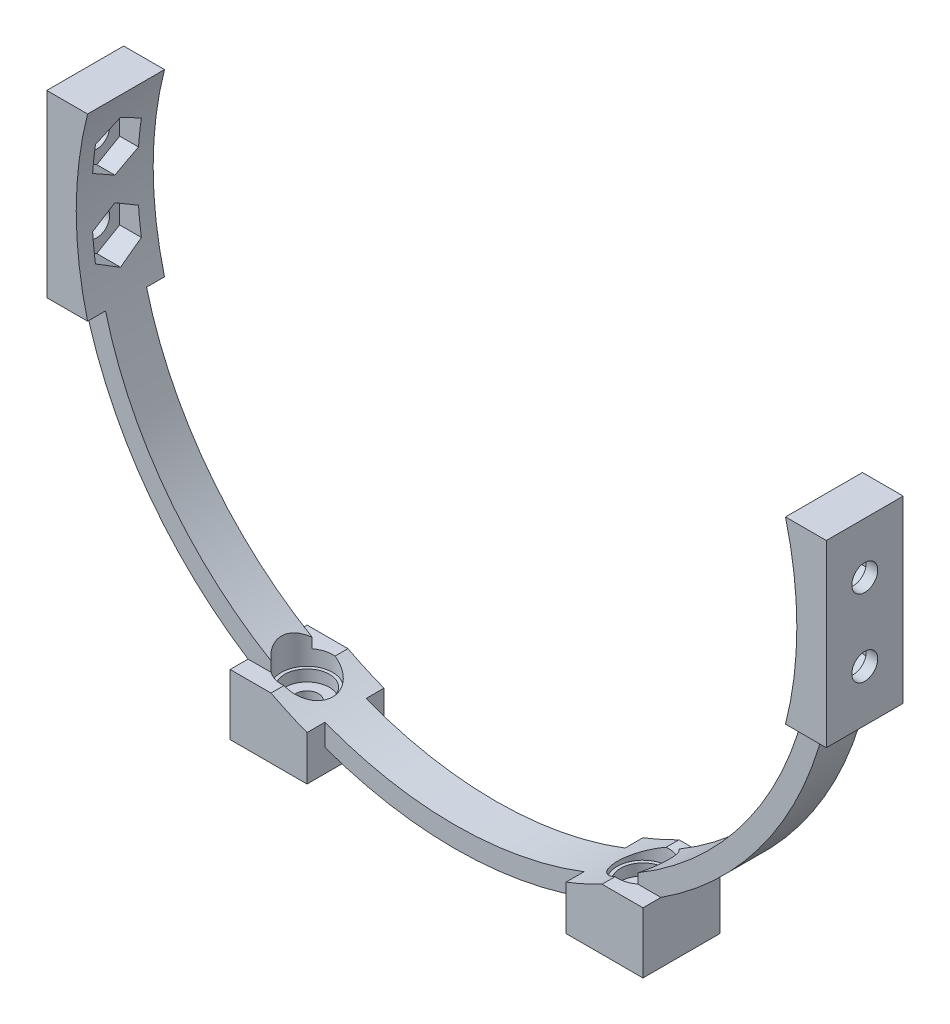
from build123d import *

# Parameters (mm, degrees)
BOSS_EXTRUDE1_DEPTH                            = 4
BOSS_EXTRUDE2_DEPTH                            = 7.5
CUT_EXTRUDE1_DEPTH                             = 3.5
F_8_0_199_DIAMETER_HOLE1_AT_2_COUNT            = 2
F_8_0_199_DIAMETER_HOLE1_AT_2_PITCH            = 15
BOSS_EXTRUDE3_REACH                            = 108.518
BOSS_EXTRUDE3_DIRECTION_2_REACH                = 108.518
SKETCH6_R                                      = 5
CUT_EXTRUDE2_DEPTH                             = 3.5
CUT_EXTRUDE2_DEPTH_BACK                        = 3
CBORE_FOR_8_BUTTON_HEAD_CAP_SCREW1_D           = 4.4958
CBORE_FOR_8_BUTTON_HEAD_CAP_SCREW1_DEPTH       = 11.649325414
CBORE_FOR_8_BUTTON_HEAD_CAP_SCREW1_CBORE_D     = 8.73252
CBORE_FOR_8_BUTTON_HEAD_CAP_SCREW1_CBORE_DEPTH = 2.2098
CBORE_FOR_8_BUTTON_HEAD_CAP_SCREW1_TIP         = 1.350674586


with BuildPart() as part:
    # Sketch1 → Boss-Extrude1 (new, symmetric)
    with BuildSketch(Plane.XY):
        with BuildLine():
            Line((-76, 17.5), (-76, 0))
            Line((-76, 0), (-76, -17.5))
            Line((-76, -17.5), (-72.163391169, -17.5))
            Line((-72.163391169, -17.5), (-68.04053957, -17.5))
            ThreePointArc((-68.04053957, -17.5), (-69.699186267, -8.81977657), (-70.255, 0))
            ThreePointArc((-70.255, 0), (-69.699186267, 8.81977657), (-68.04053957, 17.5))
            Line((-68.04053957, 17.5), (-70.255, 17.5))
            Line((-70.255, 17.5), (-76, 17.5))
        make_face()
        with BuildLine():
            Line((-68.04053957, -17.5), (-72.163391169, -17.5))
            ThreePointArc((-72.163391169, -17.5), (0, -74.255), (72.163391169, -17.5))
            Line((72.163391169, -17.5), (68.04053957, -17.5))
            ThreePointArc((68.04053957, -17.5), (0, -70.255), (-68.04053957, -17.5))
        make_face()
        with BuildLine():
            Line((68.04053957, -17.5), (72.163391169, -17.5))
            Line((72.163391169, -17.5), (76, -17.5))
            Line((76, -17.5), (76, 0))
            Line((76, 0), (76, 17.5))
            Line((76, 17.5), (70.255, 17.5))
            Line((70.255, 17.5), (68.04053957, 17.5))
            ThreePointArc((68.04053957, 17.5), (69.699186267, 8.81977657), (70.255, 0))
            ThreePointArc((70.255, 0), (69.699186267, -8.81977657), (68.04053957, -17.5))
        make_face()
    extrude(amount=BOSS_EXTRUDE1_DEPTH, both=True)

    # Sketch1_5 → Boss-Extrude2 (add, symmetric)
    with BuildSketch(Plane.XY):
        with BuildLine():
            Line((-76, 17.5), (-76, 0))
            Line((-76, 0), (-76, -17.5))
            Line((-76, -17.5), (-72.163391169, -17.5))
            Line((-72.163391169, -17.5), (-68.04053957, -17.5))
            ThreePointArc((-68.04053957, -17.5), (-69.699186267, -8.81977657), (-70.255, 0))
            ThreePointArc((-70.255, 0), (-69.699186267, 8.81977657), (-68.04053957, 17.5))
            Line((-68.04053957, 17.5), (-70.255, 17.5))
            Line((-70.255, 17.5), (-76, 17.5))
        make_face()
        with BuildLine():
            Line((68.04053957, -17.5), (72.163391169, -17.5))
            Line((72.163391169, -17.5), (76, -17.5))
            Line((76, -17.5), (76, 0))
            Line((76, 0), (76, 17.5))
            Line((76, 17.5), (70.255, 17.5))
            Line((70.255, 17.5), (68.04053957, 17.5))
            ThreePointArc((68.04053957, 17.5), (69.699186267, 8.81977657), (70.255, 0))
            ThreePointArc((70.255, 0), (69.699186267, -8.81977657), (68.04053957, -17.5))
        make_face()
    extrude(amount=BOSS_EXTRUDE2_DEPTH, both=True)

    # Sketch2 → Cut-Extrude1 (cut, symmetric)
    with BuildSketch(Plane.ZY.offset(-70.255)):
        Polygon((0, 2.332715091), (4.475, 4.916357545), (4.475, 10.083642455), (0, 12.667284909), (-4.475, 10.083642455), (-4.475, 4.916357545), align=None)
        Polygon((0, -12.667284909), (4.475, -10.083642455), (4.475, -4.916357545), (0, -2.332715091), (-4.475, -4.916357545), (-4.475, -10.083642455), align=None)
    cut_extrude1 = extrude(amount=CUT_EXTRUDE1_DEPTH, both=True, mode=Mode.SUBTRACT)

    # Sketch4 → 8 _0.199_ Diameter Hole1 (revolve, cut)
    with BuildSketch(Plane(origin=(76, 7.5, 0), x_dir=(0, 0, -1), z_dir=(0, 1, 0))):
        Polygon((0, 0), (0, 10.71), (2.5273, 9.191444958), (2.5273, 0), align=None)
    f_8_0_199_diameter_hole1 = revolve(axis=Axis((82.35, 7.5, 0), (-1, 0, 0)), mode=Mode.SUBTRACT)

    # 8 _0.199_ Diameter Hole1 at 2: 8 _0.199_ Diameter Hole1 ×2
    with Locations(*[(0, -i * F_8_0_199_DIAMETER_HOLE1_AT_2_PITCH, 0) for i in range(1, F_8_0_199_DIAMETER_HOLE1_AT_2_COUNT)]):
        add(f_8_0_199_diameter_hole1, mode=Mode.SUBTRACT)

    # Mirror1: Cut-Extrude1, 8 _0.199_ Diameter Hole1 across plane
    add(cut_extrude1.mirror(Plane(origin=(0, 0, 0), x_dir=(0, 0, 1), z_dir=(1, 0, 0))), mode=Mode.SUBTRACT)
    add(f_8_0_199_diameter_hole1.mirror(Plane(origin=(0, 0, 0), x_dir=(0, 0, 1), z_dir=(1, 0, 0))), mode=Mode.SUBTRACT)

    # Mirror1 copy 1 sketch → Mirror1 copy 1 (revolve, cut)
    with BuildSketch(Plane(origin=(-76, -7.5, 0), x_dir=(0, 0, -1), z_dir=(0, 1, 0))):
        Polygon((0, 0), (0, -10.71), (2.5273, -9.191444958), (2.5273, 0), align=None)
    revolve(axis=Axis((-82.35, -7.5, 0), (-1, 0, 0)), mode=Mode.SUBTRACT)

    # Boss-Extrude3: up to this face of the body (flat: up to its plane)
    boss_extrude3_end = Plane(part.part.faces().sort_by_distance((-72.727295349, 0, 7.5))[0])
    # Sketch5 → Boss-Extrude3 (add, up to the picked face)
    with BuildSketch(Plane.XY, mode=Mode.PRIVATE) as boss_extrude3_sk1:
        with BuildLine():
            Line((40.25, -62.399859976), (40.25, -74.255))
            Line((40.25, -74.255), (25.25, -74.255))
            Line((25.25, -74.255), (25.25, -65.560678192))
            ThreePointArc((25.25, -65.560678192), (28.808569138, -64.076761538), (32.280373294, -62.399859976))
            Line((32.280373294, -62.399859976), (40.25, -62.399859976))
        make_face()
    boss_extrude3_tool1 = split(extrude(boss_extrude3_sk1.sketch, amount=BOSS_EXTRUDE3_REACH, mode=Mode.PRIVATE), bisect_by=boss_extrude3_end, keep=Keep.BOTH, mode=Mode.PRIVATE)
    # Sketch5 → Boss-Extrude3 (add, up to the picked face)
    with BuildSketch(Plane.XY, mode=Mode.PRIVATE) as boss_extrude3_sk2:
        with BuildLine():
            Line((-25.25, -74.255), (-40.25, -74.255))
            Line((-40.25, -74.255), (-40.25, -62.399859976))
            Line((-40.25, -62.399859976), (-32.280373294, -62.399859976))
            ThreePointArc((-32.280373294, -62.399859976), (-28.808569138, -64.076761538), (-25.25, -65.560678192))
            Line((-25.25, -65.560678192), (-25.25, -74.255))
        make_face()
    boss_extrude3_tool2 = split(extrude(boss_extrude3_sk2.sketch, amount=BOSS_EXTRUDE3_REACH, mode=Mode.PRIVATE), bisect_by=boss_extrude3_end, keep=Keep.BOTH, mode=Mode.PRIVATE)
    add(boss_extrude3_tool1.solids().sort_by(Axis((33.107767, -68.667419, 0), (0, 0, 1)))[0])
    add(boss_extrude3_tool2.solids().sort_by(Axis((-33.107767, -68.667419, 0), (0, 0, 1)))[0])

    # Boss-Extrude3 direction 2: up to this face of the body (flat: up to its plane)
    boss_extrude3_direction_2_end = Plane(part.part.faces().sort_by_distance((-72.727295349, 0, -7.5))[0])
    # Sketch5 → Boss-Extrude3 direction 2 (add, up to the picked face)
    with BuildSketch(Plane.XY, mode=Mode.PRIVATE) as boss_extrude3_direction_2_sk1:
        with BuildLine():
            Line((40.25, -62.399859976), (40.25, -74.255))
            Line((40.25, -74.255), (25.25, -74.255))
            Line((25.25, -74.255), (25.25, -65.560678192))
            ThreePointArc((25.25, -65.560678192), (28.808569138, -64.076761538), (32.280373294, -62.399859976))
            Line((32.280373294, -62.399859976), (40.25, -62.399859976))
        make_face()
    boss_extrude3_direction_2_tool1 = split(extrude(boss_extrude3_direction_2_sk1.sketch, amount=-BOSS_EXTRUDE3_DIRECTION_2_REACH, mode=Mode.PRIVATE), bisect_by=boss_extrude3_direction_2_end, keep=Keep.BOTH, mode=Mode.PRIVATE)
    # Sketch5 → Boss-Extrude3 direction 2 (add, up to the picked face)
    with BuildSketch(Plane.XY, mode=Mode.PRIVATE) as boss_extrude3_direction_2_sk2:
        with BuildLine():
            Line((-25.25, -74.255), (-40.25, -74.255))
            Line((-40.25, -74.255), (-40.25, -62.399859976))
            Line((-40.25, -62.399859976), (-32.280373294, -62.399859976))
            ThreePointArc((-32.280373294, -62.399859976), (-28.808569138, -64.076761538), (-25.25, -65.560678192))
            Line((-25.25, -65.560678192), (-25.25, -74.255))
        make_face()
    boss_extrude3_direction_2_tool2 = split(extrude(boss_extrude3_direction_2_sk2.sketch, amount=-BOSS_EXTRUDE3_DIRECTION_2_REACH, mode=Mode.PRIVATE), bisect_by=boss_extrude3_direction_2_end, keep=Keep.BOTH, mode=Mode.PRIVATE)
    add(boss_extrude3_direction_2_tool1.solids().sort_by(Axis((33.107767, -68.667419, 0), (0, 0, -1)))[0])
    add(boss_extrude3_direction_2_tool2.solids().sort_by(Axis((-33.107767, -68.667419, 0), (0, 0, -1)))[0])

    # Sketch6 → Cut-Extrude2 (cut, two sides)
    with BuildSketch(Plane(origin=(0, -62.399859976, 0), x_dir=(1, 0, 0), z_dir=(0, 1, 0))) as cut_extrude2_sk:
        with Locations(Location((-32.75, 0, 0), (0, 0, 84.610530172))):
            Circle(SKETCH6_R)
        with Locations(Location((32.75, 0, 0), (0, 0, 95.389469991))):
            Circle(SKETCH6_R)
    extrude(amount=CUT_EXTRUDE2_DEPTH, mode=Mode.SUBTRACT)
    extrude(cut_extrude2_sk.sketch, amount=-CUT_EXTRUDE2_DEPTH_BACK, mode=Mode.SUBTRACT)

    # CBORE for _8 Button Head Cap Screw1
    with Locations(Plane(origin=(-32.75, -65.399859976, 0), x_dir=(0, 0, 1), z_dir=(0, 1, 0))):
        with Locations((0, 0), (0, 65.5)):
            CounterBoreHole(CBORE_FOR_8_BUTTON_HEAD_CAP_SCREW1_D / 2, CBORE_FOR_8_BUTTON_HEAD_CAP_SCREW1_CBORE_D / 2, CBORE_FOR_8_BUTTON_HEAD_CAP_SCREW1_CBORE_DEPTH, depth=CBORE_FOR_8_BUTTON_HEAD_CAP_SCREW1_DEPTH)
            with Locations((0, 0, -(CBORE_FOR_8_BUTTON_HEAD_CAP_SCREW1_DEPTH + CBORE_FOR_8_BUTTON_HEAD_CAP_SCREW1_TIP / 2))):  # 118° drill point
                Cone(0, CBORE_FOR_8_BUTTON_HEAD_CAP_SCREW1_D / 2, CBORE_FOR_8_BUTTON_HEAD_CAP_SCREW1_TIP, mode=Mode.SUBTRACT)


solid = part.part
